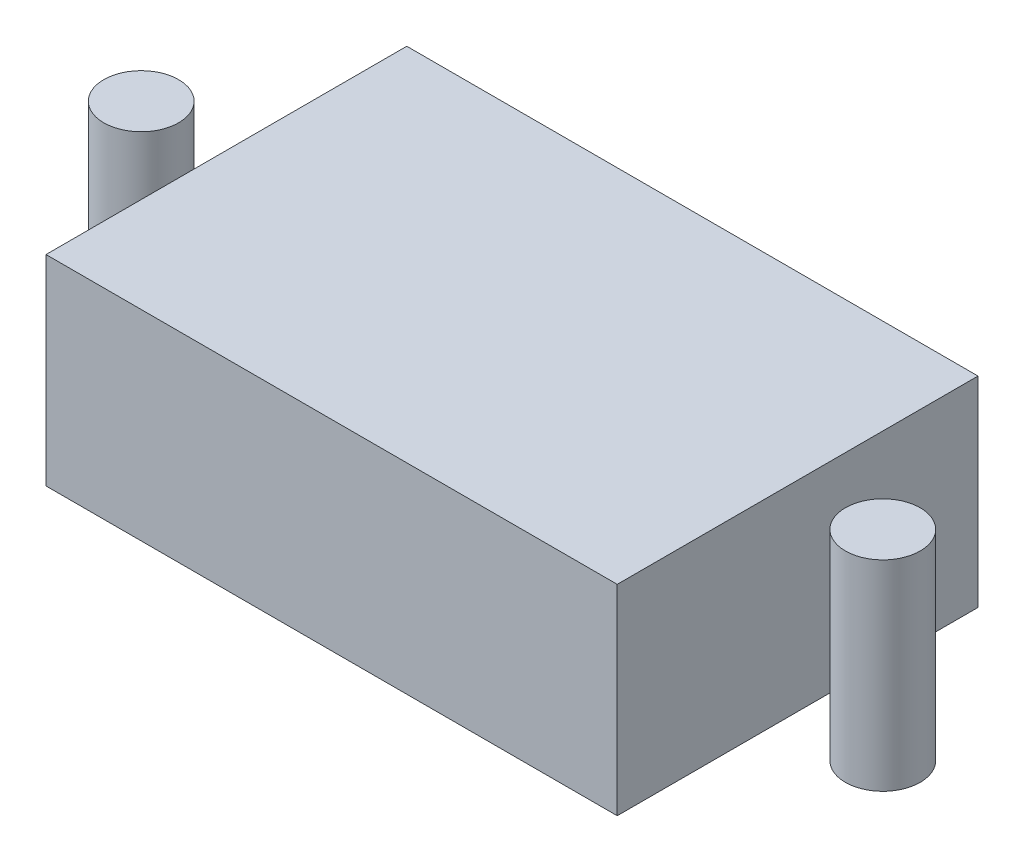
from build123d import *

# Parameters (mm, degrees)
SKETCH2_R             = 1.8669
BOSS_EXTRUDE1_DEPTH   = 10
BOSS_EXTRUDE1_2_DEPTH = 10
SKETCH2_W             = 28.5
SKETCH2_H             = 18
BOSS_EXTRUDE1_3_DEPTH = 10


with BuildPart() as part:
    # Sketch2 → Boss-Extrude1 (new body)
    with BuildSketch(Plane(origin=(0, 0, 0), x_dir=(1, 0, 0), z_dir=(0, 1, 0))):
        with Locations((18.5, 0)):
            Circle(SKETCH2_R)
    extrude(amount=BOSS_EXTRUDE1_DEPTH)


with BuildPart() as body_2:
    # Sketch2 → Boss-Extrude1 2 (new body)
    with BuildSketch(Plane(origin=(0, 0, 0), x_dir=(1, 0, 0), z_dir=(0, 1, 0))):
        with Locations((-18.5, 0)):
            Circle(SKETCH2_R)
    extrude(amount=BOSS_EXTRUDE1_2_DEPTH)


with BuildPart() as body_3:
    # Sketch2 → Boss-Extrude1 3 (new body)
    with BuildSketch(Plane(origin=(0, 0, 0), x_dir=(1, 0, 0), z_dir=(0, 1, 0))):
        Rectangle(SKETCH2_W, SKETCH2_H)
    extrude(amount=BOSS_EXTRUDE1_3_DEPTH)


solid = Compound([part.part, body_2.part, body_3.part])
